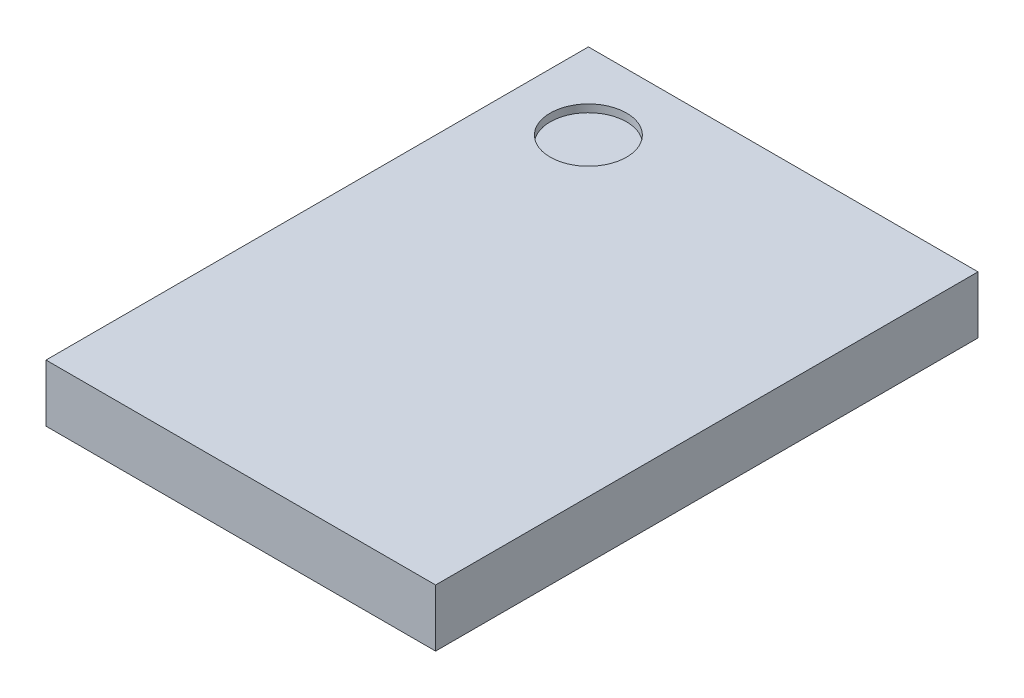
from build123d import *

# Parameters (mm, degrees)
SKETCH1_W           = 5.1
SKETCH1_H           = 7.1
BOSS_EXTRUDE1_DEPTH = 0.75
SKETCH2_R           = 0.5
CUT_EXTRUDE1_DEPTH  = 0.1


with BuildPart() as part:
    # Sketch1 → Boss-Extrude1 (new body)
    with BuildSketch(Plane(origin=(0, 0, 0), x_dir=(1, 0, 0), z_dir=(0, 1, 0))):
        Rectangle(SKETCH1_W, SKETCH1_H)
    extrude(amount=BOSS_EXTRUDE1_DEPTH)

    # Sketch2 → Cut-Extrude1 (cut)
    with BuildSketch(Plane(origin=(0, 0.75, 0), x_dir=(1, 0, 0), z_dir=(0, 1, 0))):
        with Locations((-1.55, 2.55)):
            Circle(SKETCH2_R)
    extrude(amount=-CUT_EXTRUDE1_DEPTH, mode=Mode.SUBTRACT)


solid = part.part
